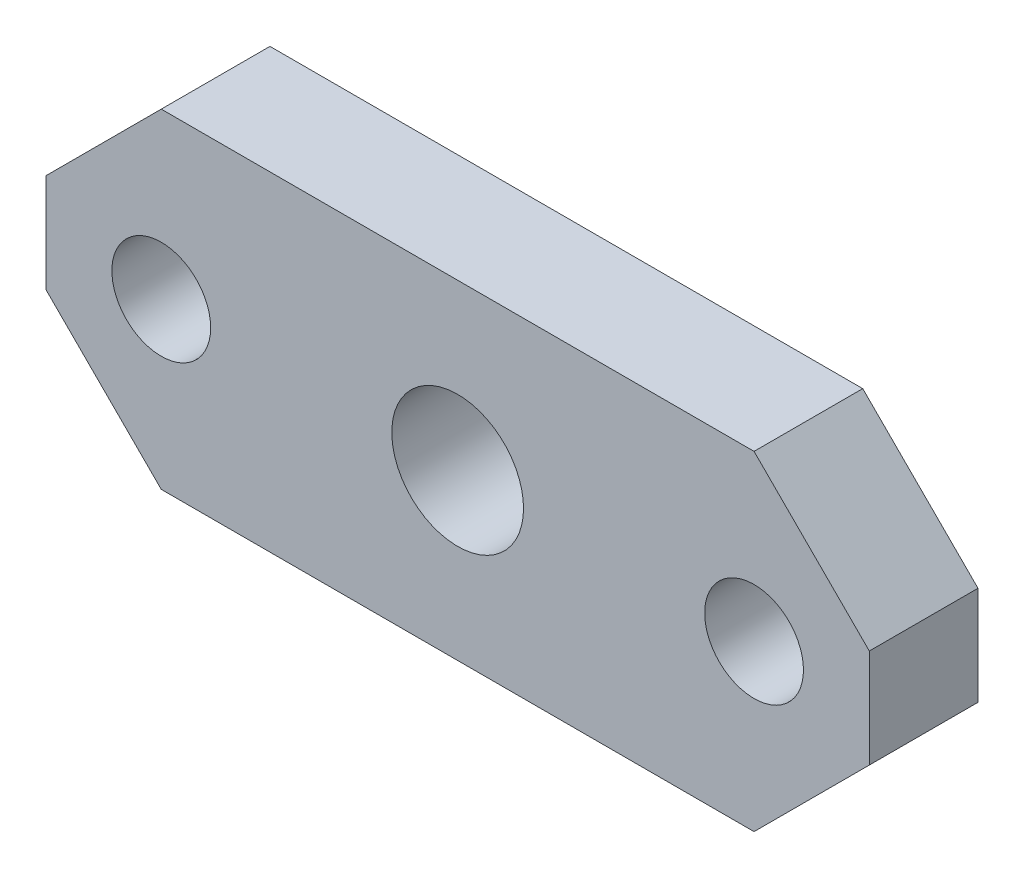
from build123d import *

# Parameters (mm, degrees)
SKETCH1_W           = 250
SKETCH1_H           = 100
BOSS_EXTRUDE1_DEPTH = 33
CHAMFER1_SIZE       = 35
SKETCH2_R           = 20
CUT_EXTRUDE1_DEPTH  = 35
SKETCH3_R           = 15
CUT_EXTRUDE2_DEPTH  = 33
LPATTERN1_COUNT     = 2
LPATTERN1_PITCH     = 180


with BuildPart() as part:
    # Sketch1 → Boss-Extrude1 (new body)
    with BuildSketch(Plane.XY):
        with Locations((14.758290847, 1.860150752)):
            Rectangle(SKETCH1_W, SKETCH1_H)
    extrude(amount=BOSS_EXTRUDE1_DEPTH)

    # Chamfer1
    chamfer1_edges = [part.edges().sort_by_distance(p)[0] for p in [
        (-110.241709153, 51.860150752, 16.5),
        (139.758290847, 51.860150752, 16.5),
        (139.758290847, -48.139849248, 16.5),
        (-110.241709153, -48.139849248, 16.5),
    ]]
    chamfer(chamfer1_edges, length=CHAMFER1_SIZE)

    # Sketch2 → Cut-Extrude1 (cut)
    with BuildSketch(Plane.XY.offset(33)):
        with Locations((14.758290847, 1.860150752)):
            Circle(SKETCH2_R)
    extrude(amount=-CUT_EXTRUDE1_DEPTH, mode=Mode.SUBTRACT)

    # Sketch3 → Cut-Extrude2 (cut)
    with BuildSketch(Plane.XY.offset(33)):
        with Locations((104.758290847, 1.860150752)):
            Circle(SKETCH3_R)
    cut_extrude2 = extrude(amount=-CUT_EXTRUDE2_DEPTH, mode=Mode.SUBTRACT)

    # LPattern1: Cut-Extrude2 ×2
    with Locations(*[(-i * LPATTERN1_PITCH, 0, 0) for i in range(1, LPATTERN1_COUNT)]):
        add(cut_extrude2, mode=Mode.SUBTRACT)


solid = part.part
